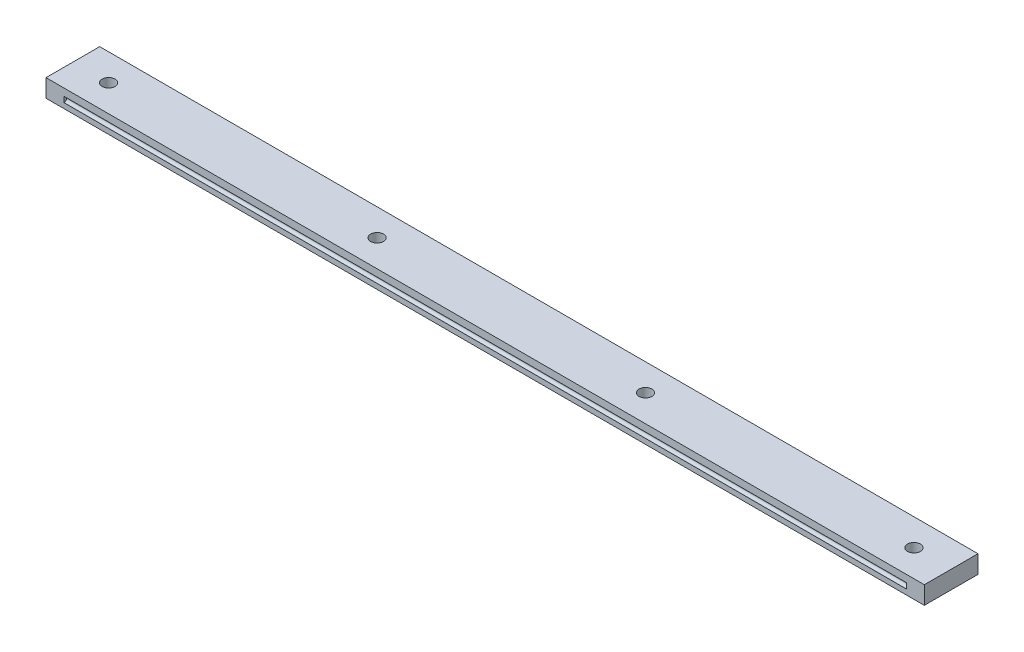
from build123d import *

# Parameters (mm, degrees)
SKETCH1_W              = 245.4
SKETCH1_H              = 5
MAIN_BODY_DEPTH        = 15
SKETCH3_R              = 1.8
SCREW_HOLES_DEPTH      = 5
SKETCH4_R              = 3
SCREW_HEAD_HOLES_DEPTH = 2
SKETCH2_W              = 235.4
SKETCH2_H              = 1.55
CHANNEL_A_DEPTH        = 0.75
CHANNEL_A_ROUND_R      = 0.7


with BuildPart() as part:
    # Sketch1 → Main_Body (new body)
    with BuildSketch(Plane.XY):
        with Locations((122.7, 2.5)):
            Rectangle(SKETCH1_W, SKETCH1_H)
    extrude(amount=MAIN_BODY_DEPTH)

    # Sketch3 → Screw_Holes (cut)
    with BuildSketch(Plane.XZ):
        with Locations((10, 7.5)):
            Circle(SKETCH3_R)
        with Locations((85, 7.5)):
            Circle(SKETCH3_R)
        with Locations((160, 7.5)):
            Circle(SKETCH3_R)
        with Locations((235, 7.5)):
            Circle(SKETCH3_R)
    extrude(amount=-SCREW_HOLES_DEPTH, mode=Mode.SUBTRACT)

    # Sketch4 → Screw_Head_Holes (cut)
    with BuildSketch(Plane.XZ):
        with Locations((10, 7.5)):
            Circle(SKETCH4_R)
        with Locations((85, 7.5)):
            Circle(SKETCH4_R)
        with Locations((160, 7.5)):
            Circle(SKETCH4_R)
        with Locations((235, 7.5)):
            Circle(SKETCH4_R)
    extrude(amount=-SCREW_HEAD_HOLES_DEPTH, mode=Mode.SUBTRACT)

    # Sketch2 → Channel_A (cut)
    with BuildSketch(Plane.XY.offset(15)):
        with Locations((122.7, 2.225)):
            Rectangle(SKETCH2_W, SKETCH2_H)
    extrude(amount=-CHANNEL_A_DEPTH, mode=Mode.SUBTRACT)

    # Channel_A_Round
    channel_a_round_edges = [part.edges().sort_by_distance(p)[0] for p in [
        (122.7, 3, 14.25),
        (122.7, 1.45, 14.25),
    ]]
    fillet(channel_a_round_edges, radius=CHANNEL_A_ROUND_R)


solid = part.part
